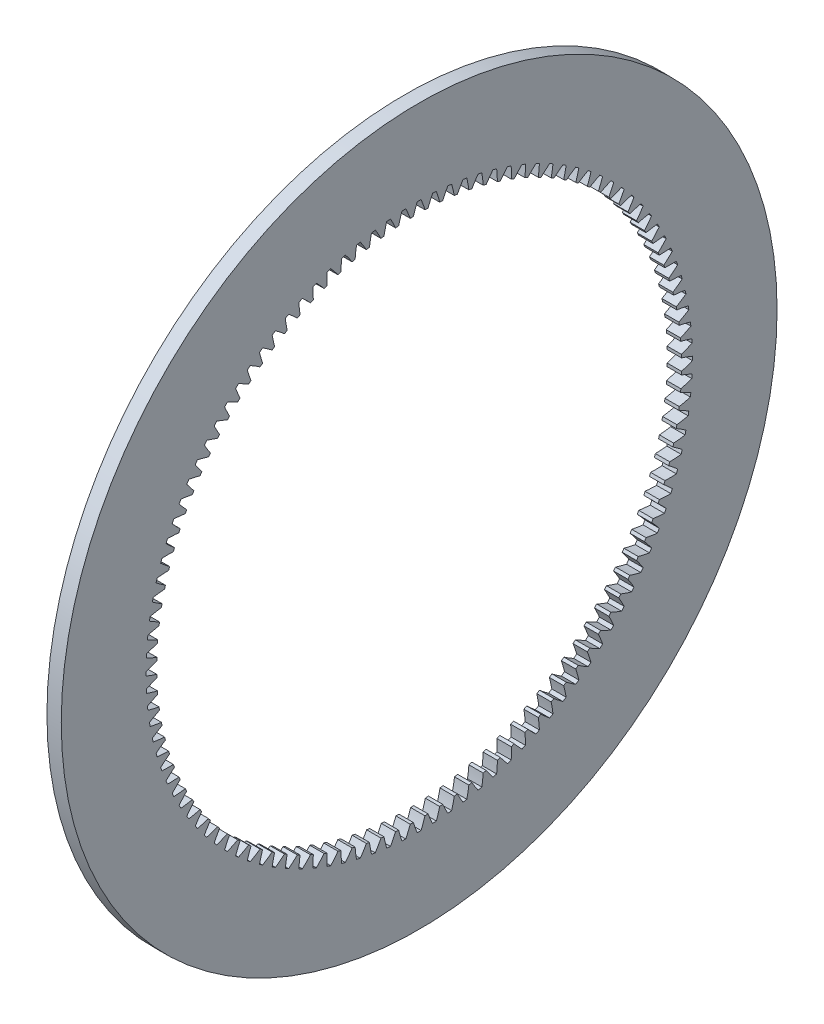
from build123d import *

# Parameters (mm, degrees)
BASPROSKE_W     = 3
BASPROSKE_H     = 20
TOOTHCUT_DEPTH  = 107.108435103
TEETHCUTS_COUNT = 112
TEETHCUTS_ANGLE = 356.785714286


with BuildPart() as part:
    # BasProSke → Base-Revolve (revolve)
    with BuildSketch(Plane(origin=(0, 0, 0), x_dir=(1, 0, 0), z_dir=(0, 1, 0)), mode=Mode.PRIVATE) as base_revolve_sk:
        with Locations((1.5, 65)):
            Rectangle(BASPROSKE_W, BASPROSKE_H)
    revolve(base_revolve_sk.sketch.rotate(Axis((-10, 0, 0), (1, 0, 0)), 180), axis=Axis((-10, 0, 0), (1, 0, 0)))

    # TooCutSke → ToothCut (cut, through all)
    with BuildSketch(Plane(origin=(0, 0, 0), x_dir=(0, 0, -1), z_dir=(1, 0, 0))):
        with BuildLine():
            ThreePointArc((1.222724284, 54.961000632), (0.837252201, 56.114205791), (0.40207647, 57.249588082))
            ThreePointArc((0.40207647, 57.249588082), (0, 57.251), (-0.40207647, 57.249588082))
            ThreePointArc((-0.40207647, 57.249588082), (-0.837252201, 56.114205791), (-1.222724284, 54.961000632))
            ThreePointArc((-1.222724284, 54.961000632), (0, 54.9746), (1.222724284, 54.961000632))
        make_face()
    toothcut = extrude(amount=TOOTHCUT_DEPTH, mode=Mode.SUBTRACT)

    # TeethCuts: ToothCut ×112 about axis
    teethcuts_axis = Axis((-10, 0, 0), (1, 0, 0))
    for i in range(1, TEETHCUTS_COUNT):
        add(toothcut.rotate(teethcuts_axis, i * TEETHCUTS_ANGLE / (TEETHCUTS_COUNT - 1)), mode=Mode.SUBTRACT)


solid = part.part
